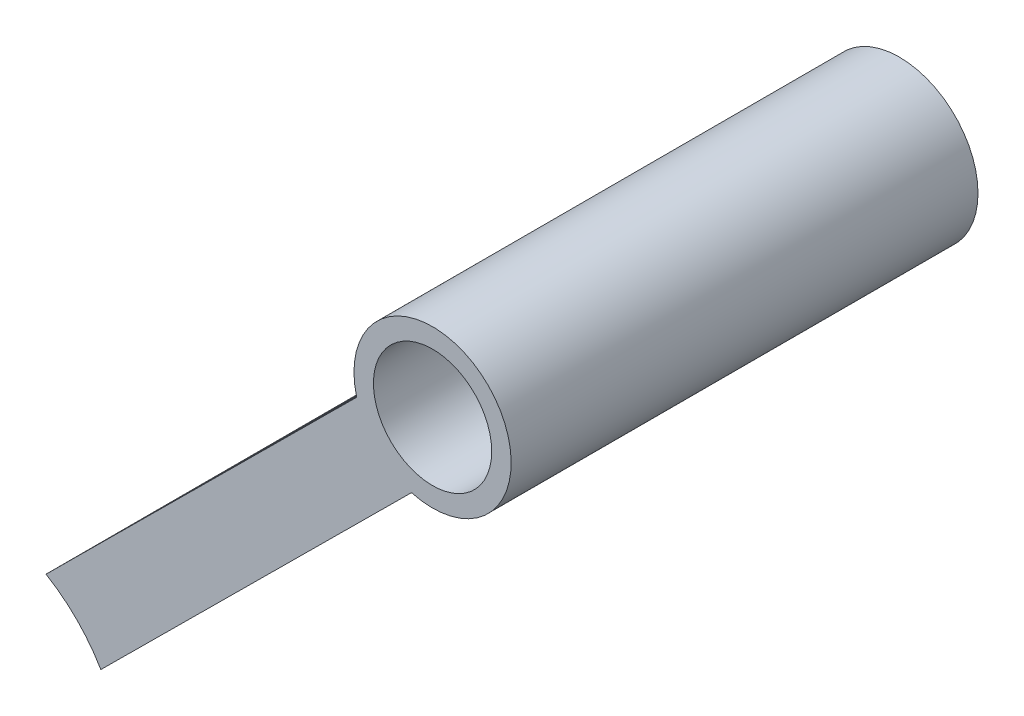
from build123d import *

# Parameters (mm, degrees)
SKETCH2_R      = 6.4135
SKETCH2_R_2    = 4.826
EXTRUDE1_DEPTH = 38.1
EXTRUDE2_DEPTH = 25.4


with BuildPart() as part:
    # Sketch2 → Extrude1 (new body)
    with BuildSketch(Plane.XY.offset(-31.75)):
        with Locations((38.035581748, 37.774829094)):
            Circle(SKETCH2_R)
        with Locations((38.035581748, 37.774829094)):
            Circle(SKETCH2_R_2, mode=Mode.SUBTRACT)
    extrude(amount=EXTRUDE1_DEPTH)

    # Sketch3 → Extrude2 (add)
    with BuildSketch(Plane.XY.offset(6.35)):
        with BuildLine():
            Line((31.844396197, 36.10085068), (6.48762227, 10.917909932))
            ThreePointArc((6.48762227, 10.917909932), (9.011090735, 8.949315268), (10.962279904, 6.412364564))
            Line((10.962279904, 6.412364564), (36.319053831, 31.595305313))
            ThreePointArc((36.319053831, 31.595305313), (33.484980926, 33.255424883), (31.844396197, 36.10085068))
        make_face()
    extrude(amount=-EXTRUDE2_DEPTH)


solid = part.part
